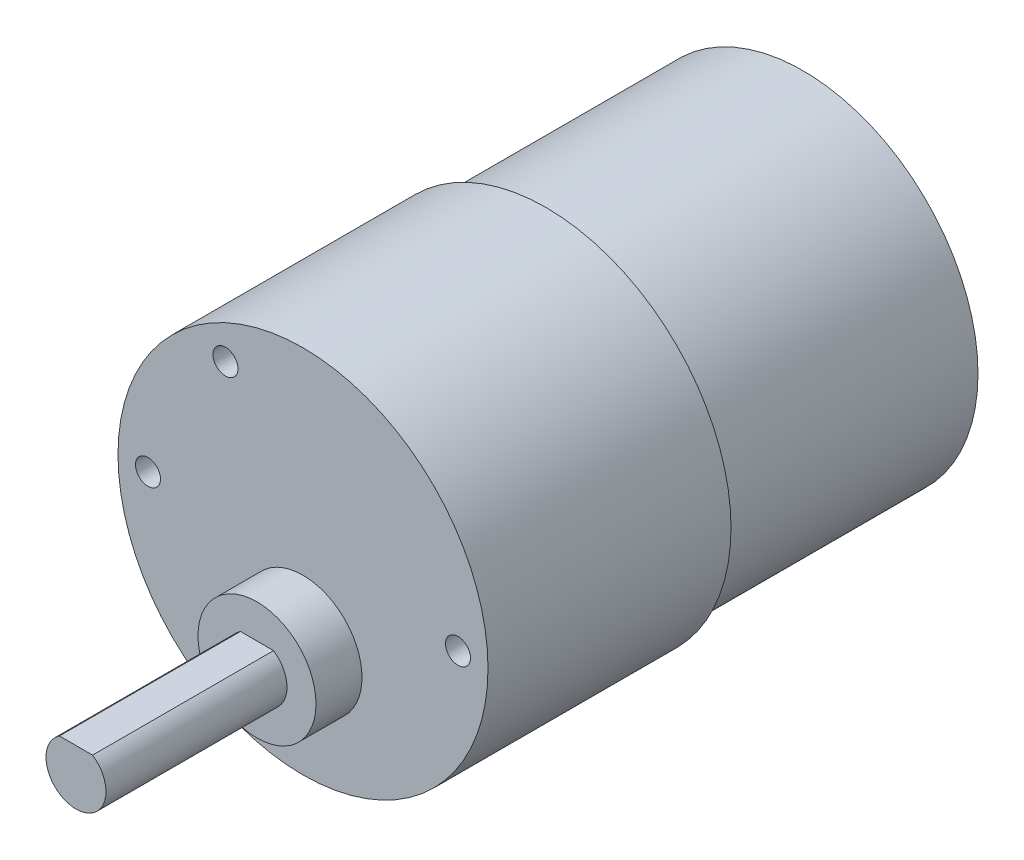
from build123d import *

# Parameters (mm, degrees)
BOSS_EXTRUDE1_DEPTH             = 22.7
SKETCH13_R                      = 5.9
BOSS_EXTRUDE2_DEPTH             = 4.6
TAP_DRILL_FOR_M3X0_5_TAP1_D     = 2.5
TAP_DRILL_FOR_M3X0_5_TAP1_DEPTH = 3
TAP_DRILL_FOR_M3X0_5_TAP1_TIP   = 0.751075774


with BuildPart() as part:
    # Sketch4 → Revolve1 (revolve)
    with BuildSketch(Plane(origin=(0, 0, 0), x_dir=(0, 0, -1), z_dir=(1, 0, 0))):
        Polygon((0, 0), (0, 18.5), (24.3, 18.5), (24.3, 17.5), (50, 17.5), (50, 0), align=None)
    revolve(axis=Axis((0, 0, 0), (0, 0, -1)))

    # Sketch12 → Boss-Extrude1 (add)
    with BuildSketch(Plane.XY):
        with BuildLine():
            Line((-1.658312395, -4.6), (1.658312395, -4.6))
            ThreePointArc((1.658312395, -4.6), (0, -10.1), (-1.658312395, -4.6))
        make_face()
    extrude(amount=BOSS_EXTRUDE1_DEPTH)

    # Sketch13 → Boss-Extrude2 (add)
    with BuildSketch(Plane.XY):
        with Locations((0, -7.1)):
            Circle(SKETCH13_R)
    extrude(amount=BOSS_EXTRUDE2_DEPTH)

    # Tap Drill for M3x0.5 Tap1
    with Locations(Plane.XY):
        with Locations((15.5, 0), (-15.5, 0), (-7.75, 13.423393759), (-7.75, -13.423393759)):
            Hole(TAP_DRILL_FOR_M3X0_5_TAP1_D / 2, depth=TAP_DRILL_FOR_M3X0_5_TAP1_DEPTH)
            with Locations((0, 0, -(TAP_DRILL_FOR_M3X0_5_TAP1_DEPTH + TAP_DRILL_FOR_M3X0_5_TAP1_TIP / 2))):  # 118° drill point
                Cone(0, TAP_DRILL_FOR_M3X0_5_TAP1_D / 2, TAP_DRILL_FOR_M3X0_5_TAP1_TIP, mode=Mode.SUBTRACT)


solid = part.part
